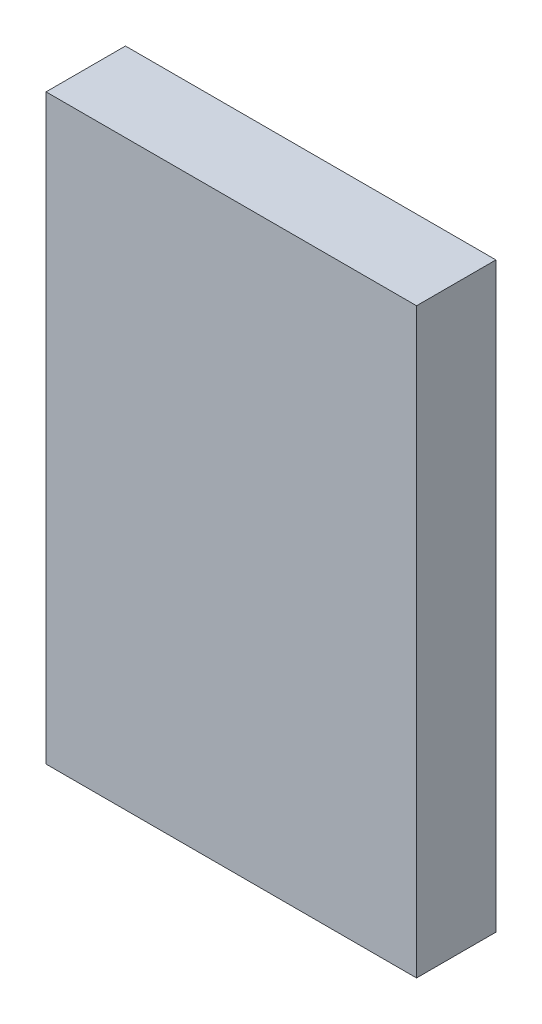
from build123d import *

# Parameters (mm, degrees)
BOSS_EXTRUDE1_START = 2
SKETCH1_W           = 21
SKETCH1_H           = 33
BOSS_EXTRUDE1_DEPTH = 4.5


with BuildPart() as part:
    # Sketch1 → Boss-Extrude1 (new body)
    with BuildSketch(Plane.XY.offset(BOSS_EXTRUDE1_START)):
        with Locations((-12.582086676, 26.406)):
            Rectangle(SKETCH1_W, SKETCH1_H)
    extrude(amount=BOSS_EXTRUDE1_DEPTH)


solid = part.part
